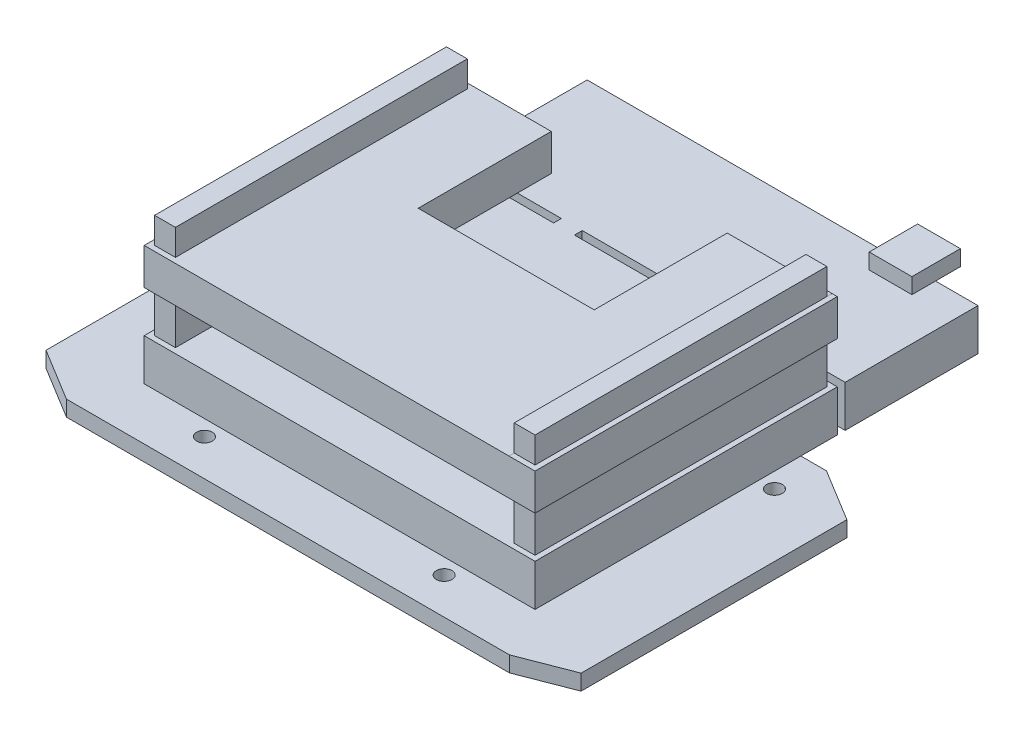
from build123d import *

# Parameters (mm, degrees)
BOSS_EXTRU_1_DEPTH      = 3
ESQUISSE2_R             = 1.5
ENL_V_MAT_EXTRU_1_DEPTH = 3
ESQUISSE3_W             = 75
ESQUISSE3_H             = 85
BOSS_EXTRU_2_DEPTH      = 8
ESQUISSE5_W             = 75
ESQUISSE5_H             = 58
BOSS_EXTRU_4_DEPTH      = 20
ESQUISSE6_R             = 3.783823372
ENL_V_MAT_EXTRU_2_DEPTH = 1
ESQUISSE8_W             = 65
ESQUISSE8_H             = 8
ESQUISSE8_H_2           = 5
ENL_V_MAT_EXTRU_3_DEPTH = 86
ESQUISSE9_W             = 58
ESQUISSE9_H             = 8
ESQUISSE9_H_2           = 5
ENL_V_MAT_EXTRU_4_DEPTH = 1
ESQUISSE10_W            = 58
ESQUISSE10_H            = 5.00265017
ESQUISSE10_H_2          = 8
ENL_V_MAT_EXTRU_5_DEPTH = 1
ESQUISSE11_W            = 4
ESQUISSE11_H            = 5
ESQUISSE11_H_2          = 8
ENL_V_MAT_EXTRU_6_DEPTH = 1
ESQUISSE12_W            = 4
ESQUISSE12_H            = 5
ESQUISSE12_H_2          = 8
ESQUISSE12_H_3          = 5.00265017
ENL_V_MAT_EXTRU_7_DEPTH = 1
ESQUISSE13_W            = 33.774018013
ESQUISSE13_H            = 51.072823149
ENL_V_MAT_EXTRU_8_DEPTH = 8
ESQUISSE14_W            = 20.555972115
ESQUISSE14_H            = 1.5
ESQUISSE14_W_2          = 21.85857566
ESQUISSE14_W_3          = 24.585452225
ENL_V_MAT_EXTRU_9_DEPTH = 8
ESQUISSE15_W            = 8.195150742
ESQUISSE15_H            = 9.302603545
BOSS_EXTRU_5_DEPTH      = 3


with BuildPart() as part:
    # Esquisse1 → Boss.-Extru.1 (new body)
    with BuildSketch(Plane(origin=(0, 0, 0), x_dir=(1, 0, 0), z_dir=(0, 1, 0))):
        Polygon((-53.560263118, 14.694067924), (-43.639645315, 18.536411574), (41.360354685, 18.536411574), (51.439736882, 12.378755225), (51.439736882, -38.621244775), (41.519119079, -42.463588426), (-43.480880921, -42.463588426), (-53.560263118, -36.305932076), align=None)
    extrude(amount=BOSS_EXTRU_1_DEPTH)

    # Esquisse2 → Enlèv. mat.-Extru.1 (cut)
    with BuildSketch(Plane(origin=(0, 3, 0), x_dir=(1, 0, 0), z_dir=(0, 1, 0))):
        with Locations((39.381313418, 10.536411574)):
            Circle(ESQUISSE2_R)
        with Locations((-41.618686582, 10.536411574)):
            Circle(ESQUISSE2_R)
        with Locations((-23.999021885, -35.463588426)):
            Circle(ESQUISSE2_R)
        with Locations((22.000978115, -35.463588426)):
            Circle(ESQUISSE2_R)
    extrude(amount=-ENL_V_MAT_EXTRU_1_DEPTH, mode=Mode.SUBTRACT)

    # Esquisse3 → Boss.-Extru.2 (add)
    with BuildSketch(Plane(origin=(0, 3, 0), x_dir=(1, 0, 0), z_dir=(0, 1, 0))):
        with Locations((-1.060263118, 10.036411574)):
            Rectangle(ESQUISSE3_W, ESQUISSE3_H)
    extrude(amount=BOSS_EXTRU_2_DEPTH)

    # Esquisse5 → Boss.-Extru.4 (add)
    with BuildSketch(Plane(origin=(0, 11, 0), x_dir=(1, 0, 0), z_dir=(0, 1, 0))):
        with Locations((-1.060263118, -3.463588426)):
            Rectangle(ESQUISSE5_W, ESQUISSE5_H)
    extrude(amount=BOSS_EXTRU_4_DEPTH)

    # Esquisse6 → Enlèv. mat.-Extru.2 (cut)
    with BuildSketch(Plane.XZ):
        with Locations((-1.060263118, 13.121244775)):
            Circle(ESQUISSE6_R)
    extrude(amount=-ENL_V_MAT_EXTRU_2_DEPTH, mode=Mode.SUBTRACT)

    # Esquisse8 → Enlèv. mat.-Extru.3 (cut)
    with BuildSketch(Plane(origin=(0, 0, -25.536411574), x_dir=(-1, 0, 0), z_dir=(0, 0, -1))):
        with Locations((1.060263118, 15)):
            Rectangle(ESQUISSE8_W, ESQUISSE8_H)
        with Locations((1.060263118, 28.5)):
            Rectangle(ESQUISSE8_W, ESQUISSE8_H_2)
    extrude(amount=-ENL_V_MAT_EXTRU_3_DEPTH, mode=Mode.SUBTRACT)

    # Esquisse9 → Enlèv. mat.-Extru.4 (cut)
    with BuildSketch(Plane.ZY.offset(38.560263118)):
        with Locations((3.463588426, 15)):
            Rectangle(ESQUISSE9_W, ESQUISSE9_H)
        with Locations((3.463588426, 28.5)):
            Rectangle(ESQUISSE9_W, ESQUISSE9_H_2)
    extrude(amount=-ENL_V_MAT_EXTRU_4_DEPTH, mode=Mode.SUBTRACT)

    # Esquisse10 → Enlèv. mat.-Extru.5 (cut)
    with BuildSketch(Plane(origin=(36.439736882, 0, 0), x_dir=(0, 0, -1), z_dir=(1, 0, 0))):
        with Locations((-3.463588426, 28.498674915)):
            Rectangle(ESQUISSE10_W, ESQUISSE10_H)
        with Locations((-3.463588426, 15)):
            Rectangle(ESQUISSE10_W, ESQUISSE10_H_2)
    extrude(amount=-ENL_V_MAT_EXTRU_5_DEPTH, mode=Mode.SUBTRACT)

    # Esquisse11 → Enlèv. mat.-Extru.6 (cut)
    with BuildSketch(Plane(origin=(0, 0, -25.536411574), x_dir=(-1, 0, 0), z_dir=(0, 0, -1))):
        with Locations((-33.439736882, 28.5)):
            Rectangle(ESQUISSE11_W, ESQUISSE11_H)
        with Locations((-33.439736882, 15)):
            Rectangle(ESQUISSE11_W, ESQUISSE11_H_2)
        with Locations((35.560263118, 15)):
            Rectangle(ESQUISSE11_W, ESQUISSE11_H_2)
        with Locations((35.560263118, 28.5)):
            Rectangle(ESQUISSE11_W, ESQUISSE11_H)
    extrude(amount=-ENL_V_MAT_EXTRU_6_DEPTH, mode=Mode.SUBTRACT)

    # Esquisse12 → Enlèv. mat.-Extru.7 (cut)
    with BuildSketch(Plane.XY.offset(32.463588426)):
        with Locations((-35.560263118, 28.5)):
            Rectangle(ESQUISSE12_W, ESQUISSE12_H)
        with Locations((-35.560263118, 15)):
            Rectangle(ESQUISSE12_W, ESQUISSE12_H_2)
        with Locations((33.439736882, 28.498674915)):
            Rectangle(ESQUISSE12_W, ESQUISSE12_H_3)
        with Locations((33.439736882, 15)):
            Rectangle(ESQUISSE12_W, ESQUISSE12_H_2)
    extrude(amount=-ENL_V_MAT_EXTRU_7_DEPTH, mode=Mode.SUBTRACT)

    # Esquisse13 → Enlèv. mat.-Extru.8 (cut)
    with BuildSketch(Plane(origin=(0, 26, 0), x_dir=(1, 0, 0), z_dir=(0, 1, 0))):
        with Locations((-1.560263118, 25.536411575)):
            Rectangle(ESQUISSE13_W, ESQUISSE13_H)
    extrude(amount=-ENL_V_MAT_EXTRU_8_DEPTH, mode=Mode.SUBTRACT)

    # Esquisse14 → Enlèv. mat.-Extru.9 (cut)
    with BuildSketch(Plane(origin=(0, 11, 0), x_dir=(1, 0, 0), z_dir=(0, 1, 0))):
        with Locations((-28.282277061, 26.286411574)):
            Rectangle(ESQUISSE14_W, ESQUISSE14_H)
        with Locations((25.510449052, 26.286411574)):
            Rectangle(ESQUISSE14_W_2, ESQUISSE14_H)
        with Locations((-1.711564891, 26.286411574)):
            Rectangle(ESQUISSE14_W_3, ESQUISSE14_H)
    extrude(amount=-ENL_V_MAT_EXTRU_9_DEPTH, mode=Mode.SUBTRACT)

    # Esquisse15 → Boss.-Extru.5 (add)
    with BuildSketch(Plane(origin=(0, 11, 0), x_dir=(1, 0, 0), z_dir=(0, 1, 0))):
        with Locations((24.189660789, 52.656882102)):
            Rectangle(ESQUISSE15_W, ESQUISSE15_H)
    extrude(amount=BOSS_EXTRU_5_DEPTH)


solid = part.part
